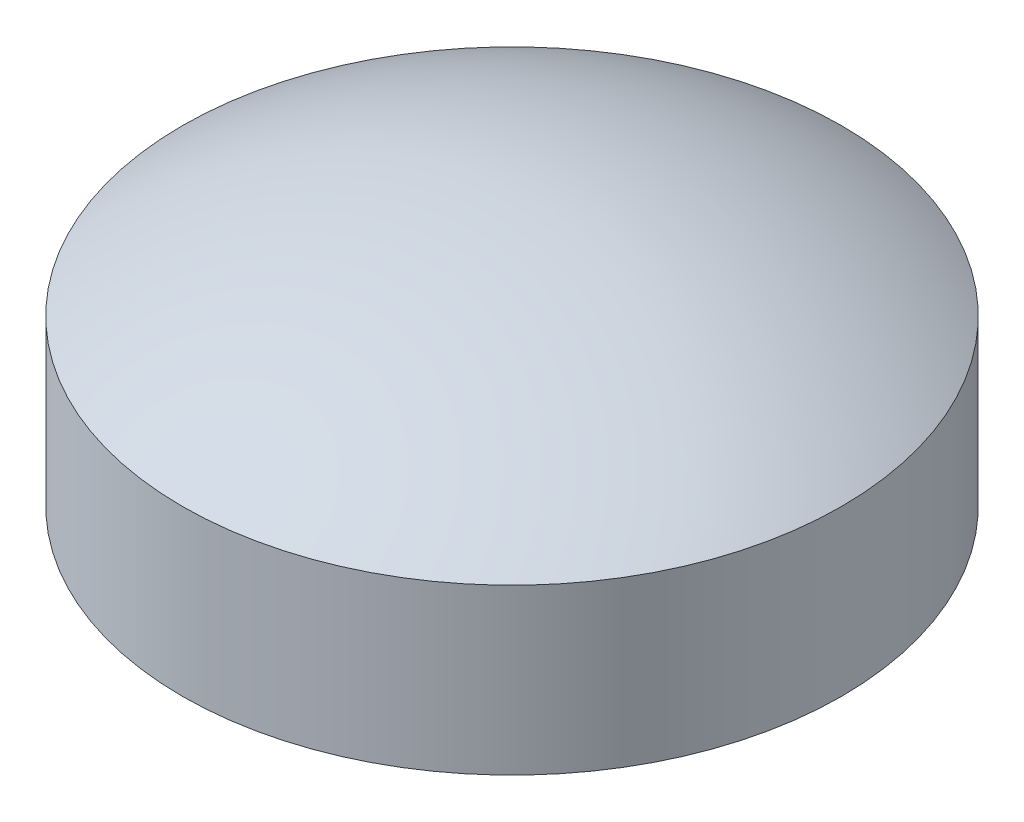
from build123d import *

# Parameters (mm, degrees)
SKIZZE1_R                       = 20.044983551
AUFSATZ_LINEAR_AUSTRAGEN1_DEPTH = 10
KUPPEL1_FACE_RADIUS             = 20.044983551
KUPPEL1_HEIGHT                  = 6


with BuildPart() as part:
    # Skizze1 → Aufsatz-Linear austragen1 (new body)
    with BuildSketch(Plane(origin=(0, 0, 0), x_dir=(1, 0, 0), z_dir=(0, 1, 0))):
        with Locations(Location((0, 0, 0), (0, 0, 270))):  # turned: the seam where the file's is
            Circle(SKIZZE1_R)
    extrude(amount=AUFSATZ_LINEAR_AUSTRAGEN1_DEPTH)

    # Kuppel1: a dome of height H over a round flat face of radius A is a cap of a sphere of radius (A * A + H * H) / (2 * H)
    kuppel1_r = (KUPPEL1_FACE_RADIUS * KUPPEL1_FACE_RADIUS + KUPPEL1_HEIGHT * KUPPEL1_HEIGHT) / (2 * KUPPEL1_HEIGHT)
    kuppel1_base = Plane((0, 10, 0), z_dir=(0, 1, 0))
    with Locations(kuppel1_base.offset(KUPPEL1_HEIGHT - kuppel1_r)):
        kuppel1_ball = Sphere(kuppel1_r, mode=Mode.PRIVATE)
    add(split(kuppel1_ball, bisect_by=kuppel1_base, keep=Keep.TOP, mode=Mode.PRIVATE))


solid = part.part
